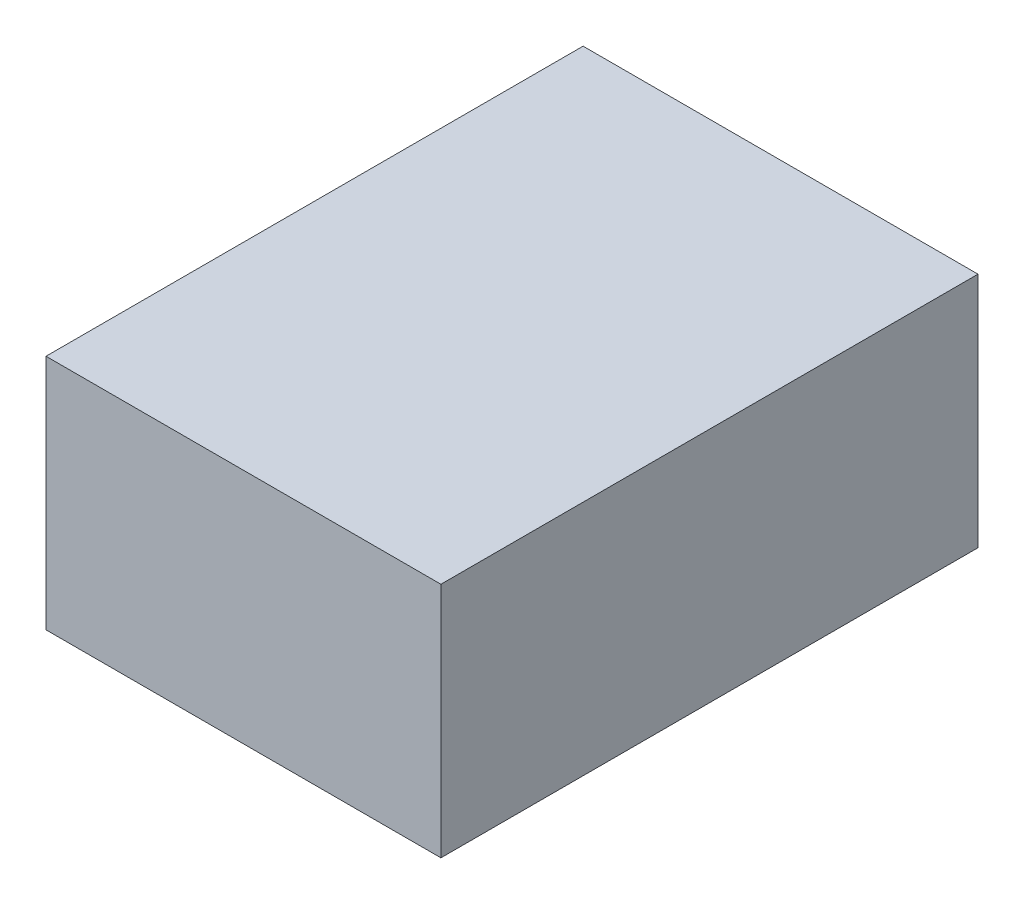
from build123d import *

# Parameters (mm, degrees)
SKETCH1_W           = 63.5
SKETCH1_H           = 86.36
BOSS_EXTRUDE1_DEPTH = 38.1


with BuildPart() as part:
    # Sketch1 → Boss-Extrude1 (new body)
    with BuildSketch(Plane(origin=(0, 0, 0), x_dir=(1, 0, 0), z_dir=(0, 1, 0))):
        with Locations((31.75, 43.18)):
            Rectangle(SKETCH1_W, SKETCH1_H)
    extrude(amount=BOSS_EXTRUDE1_DEPTH)


solid = part.part
